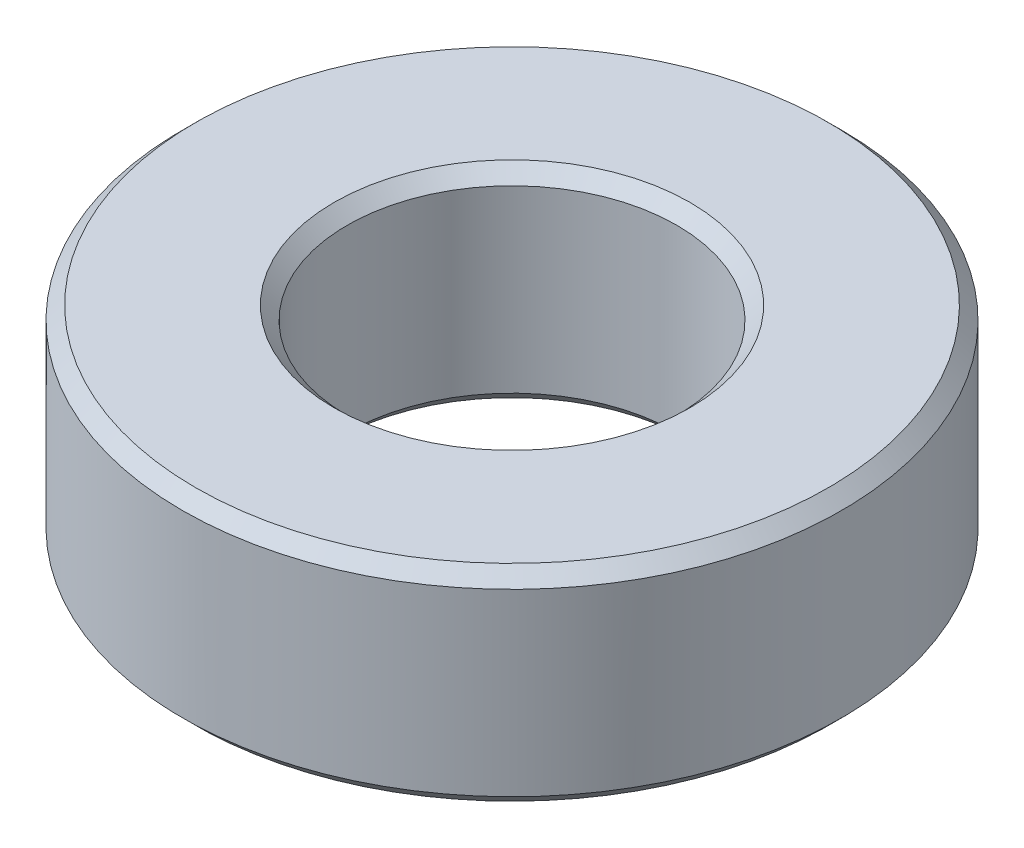
from build123d import *

# Parameters (mm, degrees)
SKETCH1_W     = 3.175
SKETCH1_H     = 3.96875
CHAMFER1_SIZE = 0.254


with BuildPart() as part:
    # Sketch1 → Revolve1 (revolve)
    with BuildSketch(Plane.XY):
        with Locations((4.7625, 0)):
            Rectangle(SKETCH1_W, SKETCH1_H)
    revolve(axis=Axis((0, -0.65258894, 0), (0, 1, 0)))

    # Chamfer1
    chamfer1_edges = [part.edges().sort_by_distance(p)[0] for p in [
        (-6.35, 1.984375, 0),
        (-6.35, -1.984375, 0),
        (-3.175, -1.984375, 0),
        (-3.175, 1.984375, 0),
    ]]
    chamfer(chamfer1_edges, length=CHAMFER1_SIZE)


solid = part.part
